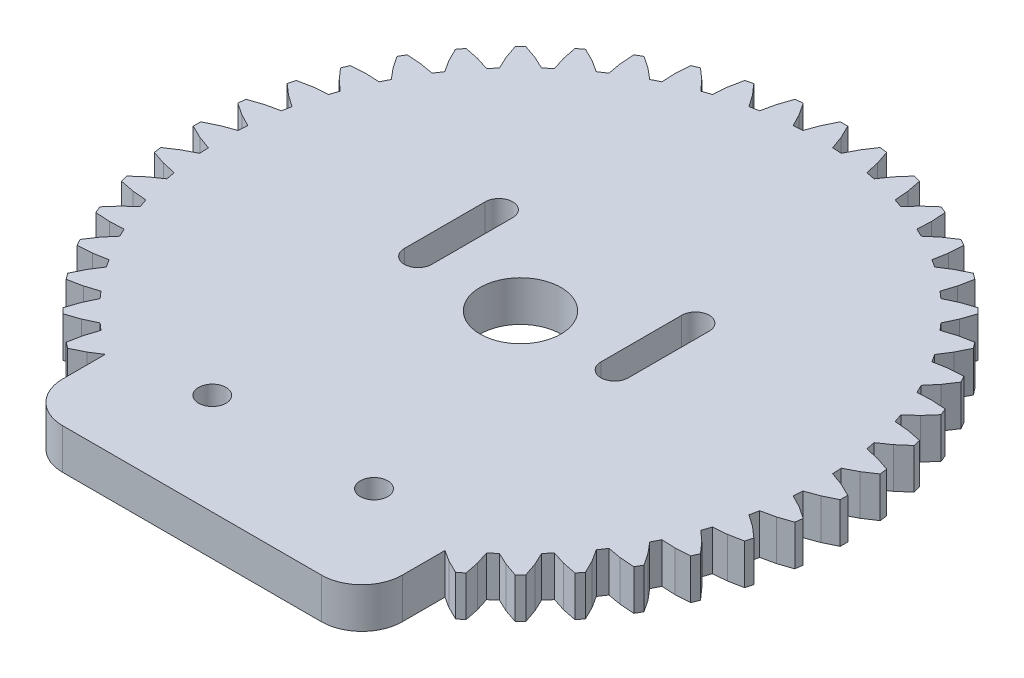
from build123d import *

# Parameters (mm, degrees)
SKETCH2_R           = 5
BOSS_EXTRUDE3_DEPTH = 5
SKETCH8_W           = 42
SKETCH8_H           = 25
BOSS_EXTRUDE4_DEPTH = 5
SKETCH7_R           = 1.7
CUT_EXTRUDE1_DEPTH  = 6
CUT_EXTRUDE2_REACH  = 7
SKETCH10_R          = 1.7
FILLET1_R           = 5


with BuildPart() as part:
    # Sketch2 → Boss-Extrude3 (new body)
    with BuildSketch(Plane(origin=(0, 0, 0), x_dir=(1, 0, 0), z_dir=(0, 1, 0))):
        Polygon((83.883520985, 67.190967342), (85.509218504, 66.606087932), (87.12712424, 65.81384946), (87.12712424, 64.885382569), (85.509218504, 64.093144098), (83.883520985, 63.508265133), (83.809500373, 62.377590807), (85.344838937, 61.585478354), (86.845618103, 60.588770789), (86.724344494, 59.668346829), (85.016834133, 59.094024044), (83.328803678, 58.726306881), (83.107745985, 57.61498644), (84.526586737, 56.62933824), (85.884350286, 55.445253367), (85.644065171, 54.54845546), (83.876106366, 54.20197712), (82.154521099, 54.057704879), (81.790322662, 52.984840175), (83.068410345, 51.822245717), (84.26003541, 50.47114201), (83.904759808, 49.613428596), (82.10663979, 49.500574638), (80.380907485, 49.582261906), (79.879851871, 48.566075327), (80.995193776, 47.246767067), (82.000320992, 45.751643157), (81.536087769, 44.947591436), (79.738721637, 45.070373261), (78.038375193, 45.376636948), (77.408882499, 44.434597), (78.342627925, 42.980945258), (79.143914805, 41.367438153), (78.578766001, 40.630872329), (76.812818597, 40.987278982), (75.167013305, 41.512840999), (74.419891302, 40.660907968), (75.155828814, 39.09792144), (75.739702301, 37.393553086), (75.083189955, 36.73704074), (73.3788216, 37.320914227), (71.815835072, 38.056851738), (70.963902042, 37.309729735), (71.489463613, 35.663924443), (71.845870712, 33.897977039), (71.109304888, 33.332828236), (69.495797783, 34.134115116), (68.042146041, 35.067860542), (67.100106093, 34.438367848), (67.406369334, 32.738021404), (67.529151605, 30.940655272), (66.725099884, 30.476421604), (65.229975973, 31.481549264), (63.910667714, 32.59689117), (62.894481135, 32.095835556), (62.976168402, 30.370102805), (62.863314444, 28.571983233), (62.005600586, 28.216707631), (60.654497323, 29.408332695), (59.491902866, 30.686420378), (58.419037716, 30.322221941), (58.274765921, 28.600636675), (57.92828758, 26.83267787), (57.031489674, 26.592392309), (55.847404801, 27.950156304), (54.8617566, 29.368997056), (53.75043616, 29.147939363), (53.382718997, 27.459908462), (52.808396211, 25.752398547), (51.887972251, 25.631124938), (50.891264687, 27.131903658), (50.099152234, 28.667242668), (48.968477907, 28.593221611), (48.383598943, 26.967524536), (47.591360471, 25.349618801), (46.662893135, 25.349618801), (45.870655109, 26.967524536), (45.285775699, 28.593221611), (44.155101818, 28.667242668), (43.362988919, 27.131903658), (42.3662818, 25.631124938), (41.445857395, 25.752398547), (40.871535055, 27.459908462), (40.503817892, 29.147939363), (39.392497006, 29.368997056), (38.406849251, 27.950156304), (37.222764378, 26.592392309), (36.325966471, 26.83267787), (35.979487686, 28.600636675), (35.83521589, 30.322221941), (34.762351186, 30.686420378), (33.599756283, 29.408332695), (32.248653021, 28.216707631), (31.390939607, 28.571983233), (31.278085649, 30.370102805), (31.359772471, 32.095835556), (30.343586338, 32.59689117), (29.024278078, 31.481549264), (27.529154168, 30.476421604), (26.725102447, 30.940655272), (26.847884272, 32.738021404), (27.154147959, 34.438367848), (26.212108011, 35.067860542), (24.758456269, 34.134115116), (23.144948718, 33.332828236), (22.40838334, 33.897977039), (22.764789993, 35.663924443), (23.29035201, 37.309729735), (22.438418979, 38.056851738), (20.875432006, 37.320914227), (19.171064097, 36.73704074), (18.514551751, 37.393553086), (19.098425238, 39.09792144), (19.834362304, 40.660907968), (19.087240301, 41.512840999), (17.441435454, 40.987278982), (15.675487605, 40.630872329), (15.110339247, 41.367438153), (15.911626127, 42.980945258), (16.845371553, 44.434597), (16.215878859, 45.376636948), (14.51553197, 45.070373261), (12.718166283, 44.947591436), (12.253932615, 45.751643157), (13.259060275, 47.246767067), (14.374402181, 48.566075327), (13.873346567, 49.582261906), (12.147613816, 49.500574638), (10.349494244, 49.613428596), (9.994218197, 50.47114201), (11.185843706, 51.822245717), (12.463931389, 52.984840175), (12.099732952, 54.057704879), (10.37814724, 54.20197712), (8.610188881, 54.54845546), (8.36990332, 55.445253367), (9.727667315, 56.62933824), (11.146508067, 57.61498644), (10.925450374, 58.726306881), (9.237419473, 59.094024044), (7.529909558, 59.668346829), (7.408635504, 60.588770789), (8.909414669, 61.585478354), (10.444753679, 62.377590807), (10.370732622, 63.508265133), (8.745035547, 64.093144098), (7.127129812, 64.885382569), (7.127129812, 65.81384946), (8.745035547, 66.606087932), (10.370732622, 67.190967342), (10.444753679, 68.321641223), (8.909414669, 69.113754121), (7.408635504, 70.11046124), (7.529909558, 71.030885646), (9.237419473, 71.605207986), (10.925450374, 71.972925149), (11.146508067, 73.084245589), (9.727667315, 74.06989379), (8.36990332, 75.253978663), (8.610188881, 76.150776569), (10.37814724, 76.497255355), (12.099732952, 76.64152715), (12.463931389, 77.714391855), (11.185843706, 78.876986758), (9.994218197, 80.22809002), (10.349494244, 81.085803434), (12.147613816, 81.198657391), (13.873346567, 81.116970124), (14.374402181, 82.133156703), (13.259060275, 83.452464962), (12.253932615, 84.947588873), (12.718166283, 85.751640594), (14.51553197, 85.628858769), (16.215878859, 85.322595082), (16.845371553, 86.26463503), (15.911626127, 87.718286772), (15.110339247, 89.331793877), (15.675487605, 90.068359701), (17.441435454, 89.711953048), (19.087240301, 89.186391031), (19.834362304, 90.038324061), (19.098425238, 91.601311035), (18.514551751, 93.305678944), (19.171064097, 93.96219129), (20.875432006, 93.378317803), (22.438418979, 92.642380291), (23.29035201, 93.38950274), (22.764789993, 95.035307586), (22.40838334, 96.801254991), (23.144948718, 97.366403794), (24.758456269, 96.565116914), (26.212108011, 95.631371488), (27.154147959, 96.260864182), (26.847884272, 97.961211071), (26.725102447, 99.758576758), (27.529154168, 100.222810426), (29.024278078, 99.217682765), (30.343586338, 98.10234086), (31.359772471, 98.603396474), (31.278085649, 100.329129224), (31.390939607, 102.127248797), (32.248653021, 102.482524399), (33.599756283, 101.290899334), (34.762351186, 100.012811651), (35.83521589, 100.377010088), (35.979487686, 102.0985958), (36.325966471, 103.86655416), (37.222764378, 104.106839721), (38.406849251, 102.749075726), (39.392497006, 101.330234974), (40.503817892, 101.551292667), (40.871535055, 103.239323568), (41.445857395, 104.946833483), (42.3662818, 105.068107092), (43.362988919, 103.567328371), (44.155101818, 102.031989362), (45.285775699, 102.106010419), (45.870655109, 103.731707493), (46.662893135, 105.349613229), (47.591360471, 105.349613229), (48.383598943, 103.731707493), (48.968477907, 102.106010419), (50.099152234, 102.031989362), (50.891264687, 103.567328371), (51.887972251, 105.068107092), (52.808396211, 104.946833483), (53.382718997, 103.239323568), (53.75043616, 101.551292667), (54.8617566, 101.330234974), (55.847404801, 102.749075726), (57.031489674, 104.106839721), (57.92828758, 103.86655416), (58.274765921, 102.0985958), (58.419037716, 100.377010088), (59.491902866, 100.012811651), (60.654497323, 101.290899334), (62.005600586, 102.482524399), (62.863314444, 102.127248797), (62.976168402, 100.329129224), (62.894481135, 98.603396474), (63.910667714, 98.10234086), (65.229975973, 99.217682765), (66.725099884, 100.222810426), (67.529151605, 99.758576758), (67.406369334, 97.961211071), (67.100106093, 96.260864182), (68.042146041, 95.631371488), (69.495797783, 96.565116914), (71.109304888, 97.366403794), (71.845870712, 96.801254991), (71.489463613, 95.035307586), (70.963902042, 93.38950274), (71.815835072, 92.642380291), (73.3788216, 93.378317803), (75.083189955, 93.96219129), (75.739702301, 93.305678944), (75.155828814, 91.601311035), (74.419891302, 90.038324061), (75.167013305, 89.186391031), (76.812818597, 89.711953048), (78.578766001, 90.068359701), (79.143914805, 89.331793877), (78.342627925, 87.718286772), (77.408882499, 86.26463503), (78.038375193, 85.322595082), (79.738721637, 85.628858769), (81.536087769, 85.751640594), (82.000320992, 84.947588873), (80.995193776, 83.452464962), (79.879851871, 82.133156703), (80.380907485, 81.116970124), (82.10663979, 81.198657391), (83.904759808, 81.085803434), (84.26003541, 80.22809002), (83.068410345, 78.876986758), (81.790322662, 77.714391855), (82.154521099, 76.64152715), (83.876106366, 76.497255355), (85.644065171, 76.150776569), (85.884350286, 75.253978663), (84.526586737, 74.06989379), (83.107745985, 73.084245589), (83.328803678, 71.972925149), (85.016834133, 71.605207986), (86.724344494, 71.030885646), (86.845618103, 70.11046124), (85.344838937, 69.113754121), (83.809500373, 68.321641223), align=None)
        with Locations((47.127126803, 65.349616015)):
            Circle(SKETCH2_R, mode=Mode.SUBTRACT)
    extrude(amount=BOSS_EXTRUDE3_DEPTH)

    # Sketch8 → Boss-Extrude4 (add)
    with BuildSketch(Plane(origin=(0, 0, 0), x_dir=(1, 0, 0), z_dir=(0, 1, 0))):
        with Locations((47.127126803, 37.236616015)):
            Rectangle(SKETCH8_W, SKETCH8_H)
    extrude(amount=BOSS_EXTRUDE4_DEPTH)

    # Sketch7 → Cut-Extrude1 (cut, through all)
    with BuildSketch(Plane(origin=(0, 0, 0), x_dir=(1, 0, 0), z_dir=(0, 1, 0))):
        with Locations((37.127126803, 37.236616015)):
            Circle(SKETCH7_R)
        with Locations((57.127126803, 37.236616015)):
            Circle(SKETCH7_R)
    extrude(amount=CUT_EXTRUDE1_DEPTH, mode=Mode.SUBTRACT)

    # Sketch10 → Cut-Extrude2 (cut, up to next)
    with BuildSketch(Plane.XZ, mode=Mode.PRIVATE) as cut_extrude2_sk1:
        with BuildLine():
            Line((36.677126803, -69.836616015), (36.677126803, -64.836616015))
            ThreePointArc((36.677126803, -64.836616015), (34.977126803, -63.136616015), (33.277126803, -64.836616015))
            Line((33.277126803, -64.836616015), (33.277126803, -69.836616015))
            ThreePointArc((33.277126803, -69.836616015), (34.977126803, -68.136616015), (36.677126803, -69.836616015))
        make_face()
    cut_extrude2_tool1 = extrude(cut_extrude2_sk1.sketch, amount=-CUT_EXTRUDE2_REACH, mode=Mode.PRIVATE) & part.part
    add(cut_extrude2_tool1.solids().sort_by_distance((34.977127, 0, -66.001439))[0], mode=Mode.SUBTRACT)
    # Sketch10 → Cut-Extrude2 (cut, up to next)
    with BuildSketch(Plane.XZ, mode=Mode.PRIVATE) as cut_extrude2_sk2:
        with Locations((34.977126803, -69.836616015)):
            Circle(SKETCH10_R)
    cut_extrude2_tool2 = extrude(cut_extrude2_sk2.sketch, amount=-CUT_EXTRUDE2_REACH, mode=Mode.PRIVATE) & part.part
    add(cut_extrude2_tool2.solids().sort_by_distance((34.977127, 0, -69.836616))[0], mode=Mode.SUBTRACT)
    # Sketch10 → Cut-Extrude2 (cut, up to next)
    with BuildSketch(Plane.XZ, mode=Mode.PRIVATE) as cut_extrude2_sk3:
        with BuildLine():
            Line((36.677126803, -74.836616015), (36.677126803, -69.836616015))
            ThreePointArc((36.677126803, -69.836616015), (34.977126803, -71.536616015), (33.277126803, -69.836616015))
            Line((33.277126803, -69.836616015), (33.277126803, -74.836616015))
            ThreePointArc((33.277126803, -74.836616015), (34.977126803, -76.536616015), (36.677126803, -74.836616015))
        make_face()
    cut_extrude2_tool3 = extrude(cut_extrude2_sk3.sketch, amount=-CUT_EXTRUDE2_REACH, mode=Mode.PRIVATE) & part.part
    add(cut_extrude2_tool3.solids().sort_by_distance((34.977127, 0, -73.671793))[0], mode=Mode.SUBTRACT)
    # Sketch10 → Cut-Extrude2 (cut, up to next)
    with BuildSketch(Plane.XZ, mode=Mode.PRIVATE) as cut_extrude2_sk4:
        with BuildLine():
            Line((60.977126803, -69.836616015), (60.977126803, -64.836616015))
            ThreePointArc((60.977126803, -64.836616015), (59.277126803, -63.136616015), (57.577126803, -64.836616015))
            Line((57.577126803, -64.836616015), (57.577126803, -69.836616015))
            ThreePointArc((57.577126803, -69.836616015), (59.277126803, -68.136616015), (60.977126803, -69.836616015))
        make_face()
    cut_extrude2_tool4 = extrude(cut_extrude2_sk4.sketch, amount=-CUT_EXTRUDE2_REACH, mode=Mode.PRIVATE) & part.part
    add(cut_extrude2_tool4.solids().sort_by_distance((59.277127, 0, -66.001439))[0], mode=Mode.SUBTRACT)
    # Sketch10 → Cut-Extrude2 (cut, up to next)
    with BuildSketch(Plane.XZ, mode=Mode.PRIVATE) as cut_extrude2_sk5:
        with Locations((59.277126803, -69.836616015)):
            Circle(SKETCH10_R)
    cut_extrude2_tool5 = extrude(cut_extrude2_sk5.sketch, amount=-CUT_EXTRUDE2_REACH, mode=Mode.PRIVATE) & part.part
    add(cut_extrude2_tool5.solids().sort_by_distance((59.277127, 0, -69.836616))[0], mode=Mode.SUBTRACT)
    # Sketch10 → Cut-Extrude2 (cut, up to next)
    with BuildSketch(Plane.XZ, mode=Mode.PRIVATE) as cut_extrude2_sk6:
        with BuildLine():
            Line((60.977126803, -74.836616015), (60.977126803, -69.836616015))
            ThreePointArc((60.977126803, -69.836616015), (59.277126803, -71.536616015), (57.577126803, -69.836616015))
            Line((57.577126803, -69.836616015), (57.577126803, -74.836616015))
            ThreePointArc((57.577126803, -74.836616015), (59.277126803, -76.536616015), (60.977126803, -74.836616015))
        make_face()
    cut_extrude2_tool6 = extrude(cut_extrude2_sk6.sketch, amount=-CUT_EXTRUDE2_REACH, mode=Mode.PRIVATE) & part.part
    add(cut_extrude2_tool6.solids().sort_by_distance((59.277127, 0, -73.671793))[0], mode=Mode.SUBTRACT)

    # Fillet1
    fillet1_edges = [part.edges().sort_by_distance(p)[0] for p in [
        (68.127126803, 2.5, -24.736616015),
        (26.127126803, 2.5, -24.736616015),
    ]]
    fillet(fillet1_edges, radius=FILLET1_R)


solid = part.part
